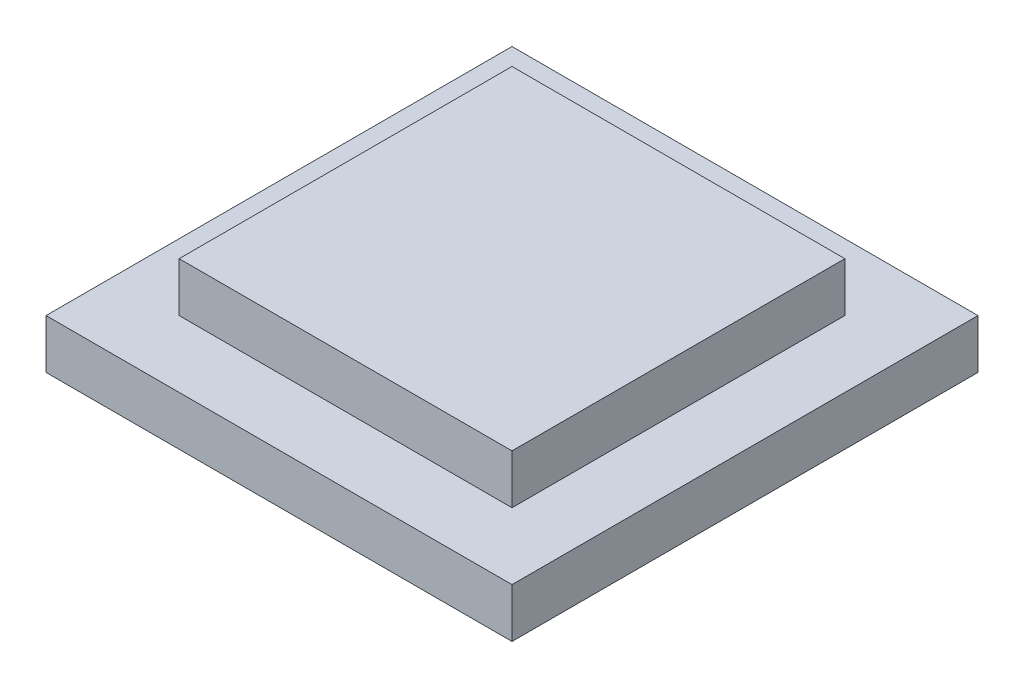
from build123d import *

# Parameters (mm, degrees)
SKETCH1_W           = 35
SKETCH1_H           = 35
BOSS_EXTRUDE1_DEPTH = 3.7
SKETCH2_W           = 25
SKETCH2_H           = 25
BOSS_EXTRUDE2_DEPTH = 3.7


with BuildPart() as part:
    # Sketch1 → Boss-Extrude1 (new body)
    with BuildSketch(Plane(origin=(0, 0, 0), x_dir=(1, 0, 0), z_dir=(0, 1, 0))):
        Rectangle(SKETCH1_W, SKETCH1_H)
    extrude(amount=BOSS_EXTRUDE1_DEPTH)

    # Sketch2 → Boss-Extrude2 (add)
    with BuildSketch(Plane(origin=(0, 3.7, 0), x_dir=(1, 0, 0), z_dir=(0, 1, 0))):
        Rectangle(SKETCH2_W, SKETCH2_H)
    extrude(amount=BOSS_EXTRUDE2_DEPTH)


solid = part.part
